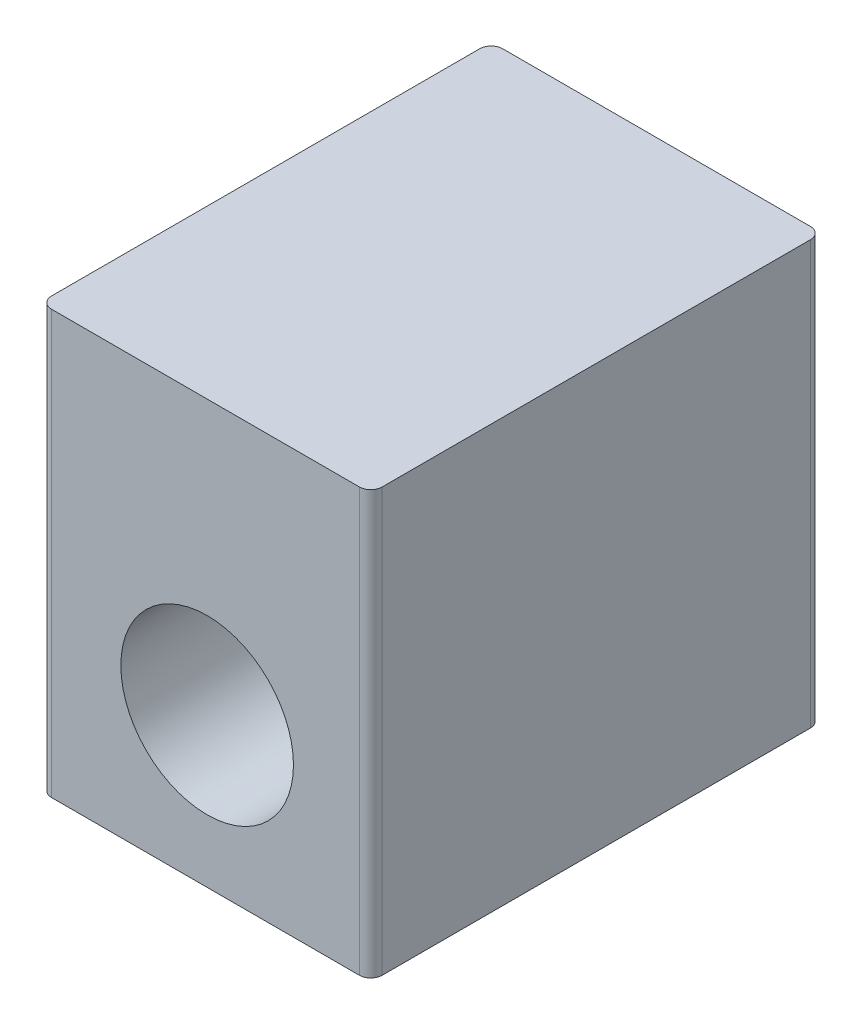
from build123d import *

# Parameters (mm, degrees)
SKETCH1_W           = 22.0472
SKETCH1_H           = 30.0736
BOSS_EXTRUDE1_DEPTH = 28.194
SKETCH2_R           = 1.5875
CUT_EXTRUDE1_DEPTH  = 4.826
SKETCH3_R           = 5.7531
CUT_EXTRUDE2_DEPTH  = 13.462
SKETCH4_R           = 5.7531
CUT_EXTRUDE3_DEPTH  = 13.462
FILLET1_R           = 0.762


with BuildPart() as part:
    # Sketch1 → Boss-Extrude1 (new body)
    with BuildSketch(Plane(origin=(0, 0, 0), x_dir=(1, 0, 0), z_dir=(0, 1, 0))):
        with Locations((11.0236, 15.0368)):
            Rectangle(SKETCH1_W, SKETCH1_H)
    extrude(amount=BOSS_EXTRUDE1_DEPTH)

    # Sketch2 → Cut-Extrude1 (cut)
    with BuildSketch(Plane.XZ):
        with Locations((3.2131, -5.2705)):
            Circle(SKETCH2_R)
        with Locations((18.7071, -5.2705)):
            Circle(SKETCH2_R)
    extrude(amount=-CUT_EXTRUDE1_DEPTH, mode=Mode.SUBTRACT)

    # Sketch3 → Cut-Extrude2 (cut)
    with BuildSketch(Plane.XY):
        with Locations((11.1379, 9.9441)):
            Circle(SKETCH3_R)
    extrude(amount=-CUT_EXTRUDE2_DEPTH, mode=Mode.SUBTRACT)

    # Sketch4 → Cut-Extrude3 (cut)
    with BuildSketch(Plane(origin=(0, 0, -30.0736), x_dir=(-1, 0, 0), z_dir=(0, 0, -1))):
        with Locations((-10.9093, 9.7917)):
            Circle(SKETCH4_R)
    extrude(amount=-CUT_EXTRUDE3_DEPTH, mode=Mode.SUBTRACT)

    # Fillet1
    fillet1_edges = [part.edges().sort_by_distance(p)[0] for p in [
        (0, 14.097, -30.0736),
        (22.0472, 14.097, -30.0736),
        (22.0472, 14.097, 0),
        (0, 14.097, 0),
    ]]
    fillet(fillet1_edges, radius=FILLET1_R)


solid = part.part
